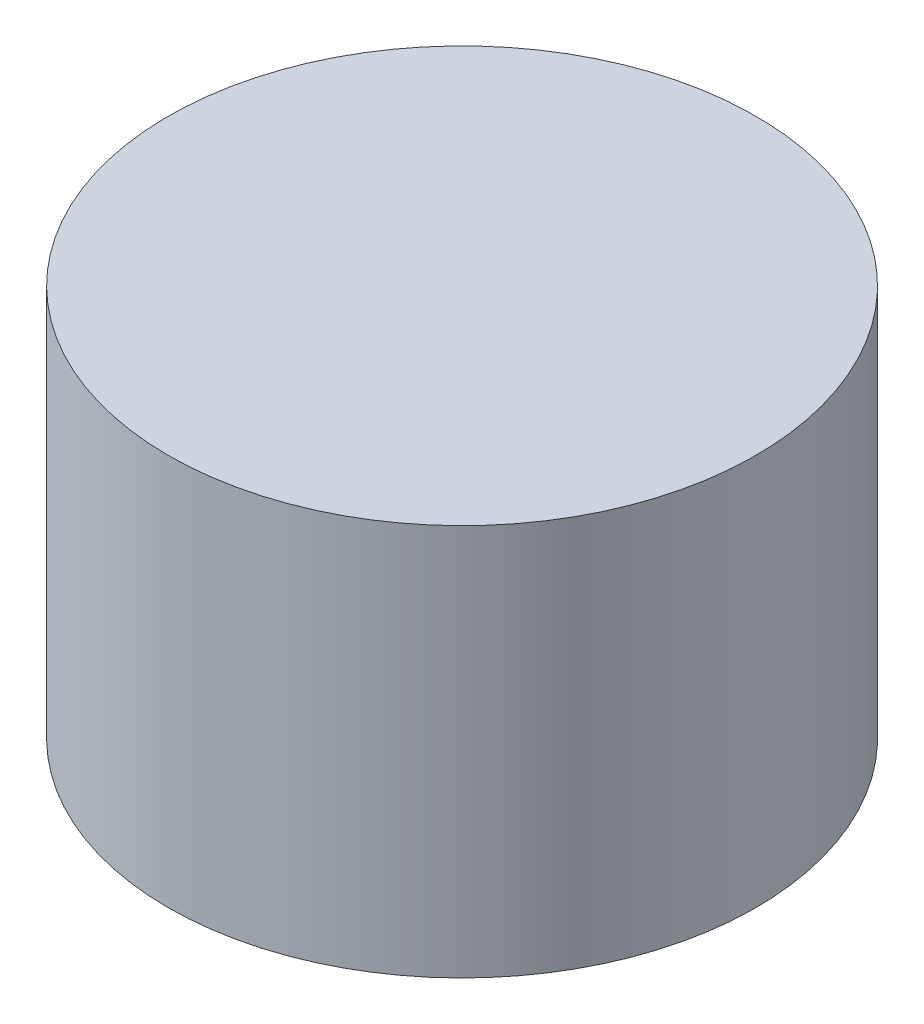
from build123d import *

# Parameters (mm, degrees)
SKETCH1_R           = 4.5
BOSS_EXTRUDE1_DEPTH = 6


with BuildPart() as part:
    # Sketch1 → Boss-Extrude1 (new body)
    with BuildSketch(Plane(origin=(0, 0, 0), x_dir=(1, 0, 0), z_dir=(0, 1, 0))):
        Circle(SKETCH1_R)
    extrude(amount=BOSS_EXTRUDE1_DEPTH)


solid = part.part
